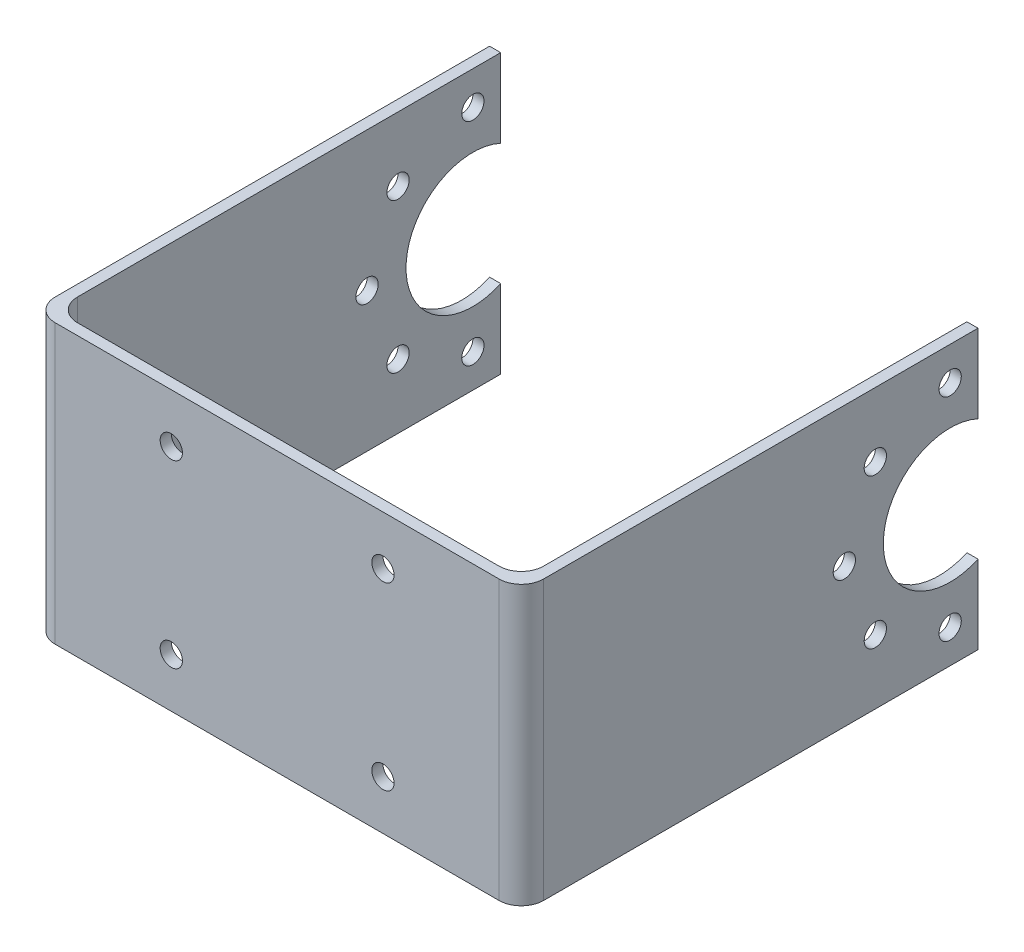
from build123d import *

# Parameters (mm, degrees)
BOSS_EXTRUDE1_DEPTH = 25
SKETCH2_R           = 1
SKETCH2_R_2         = 6
CUT_EXTRUDE1_DEPTH  = 44.85
FILLET2_R           = 2
SKETCH3_R           = 1
CUT_EXTRUDE2_DEPTH  = 42


with BuildPart() as part:
    # Sketch1 → Boss-Extrude1 (new body)
    with BuildSketch(Plane(origin=(0, 0, 0), x_dir=(1, 0, 0), z_dir=(0, 1, 0))):
        Polygon((-21.5, 0.5), (20.35, 0.5), (20.35, 40.5), (21.35, 40.5), (21.35, 0.5), (21.35, -0.5), (-22.5, -0.5), (-22.5, 0.5), (-22.5, 40.5), (-21.5, 40.5), align=None)
    extrude(amount=BOSS_EXTRUDE1_DEPTH)

    # Sketch2 → Cut-Extrude1 (cut, through all)
    with BuildSketch(Plane(origin=(21.35, 0, 0), x_dir=(0, 0, -1), z_dir=(1, 0, 0))):
        with Locations((28.5, 12.5)):
            Circle(SKETCH2_R)
        with Locations((38, 12.5)):
            Circle(SKETCH2_R_2)
        with Locations((31.282485579, 19.217514421)):
            Circle(SKETCH2_R)
        with Locations((38, 22)):
            Circle(SKETCH2_R)
        with Locations((38, 3)):
            Circle(SKETCH2_R)
        with Locations((31.282485579, 5.782485579)):
            Circle(SKETCH2_R)
    extrude(amount=-CUT_EXTRUDE1_DEPTH, mode=Mode.SUBTRACT)

    # Fillet2
    fillet2_edges = [part.edges().sort_by_distance(p)[0] for p in [
        (21.35, 12.5, 0.5),
        (-22.5, 12.5, 0.5),
        (-21.5, 12.5, -0.5),
        (20.35, 12.5, -0.5),
    ]]
    fillet(fillet2_edges, radius=FILLET2_R)

    # Sketch3 → Cut-Extrude2 (cut, through all)
    with BuildSketch(Plane.XY.offset(0.5)):
        with Locations((-10.075, 20.585)):
            Circle(SKETCH3_R)
        with Locations((8.925, 20.585)):
            Circle(SKETCH3_R)
        with Locations((-10.075, 4.415)):
            Circle(SKETCH3_R)
        with Locations((8.925, 4.415)):
            Circle(SKETCH3_R)
    extrude(amount=-CUT_EXTRUDE2_DEPTH, mode=Mode.SUBTRACT)


solid = part.part
